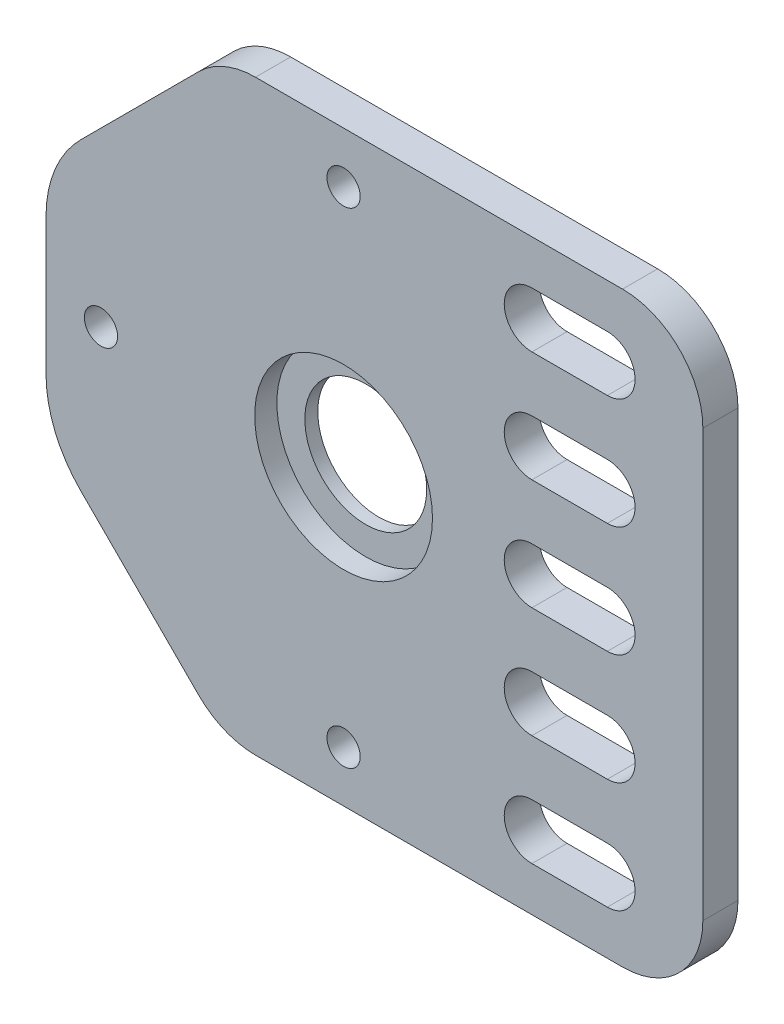
from build123d import *

# Parameters (mm, degrees)
SKETCH1_R           = 5.5
SKETCH1_R_2         = 1.5
BOSS_EXTRUDE1_DEPTH = 1.585
SKETCH3_R           = 8.025
CUT_EXTRUDE1_DEPTH  = 2


with BuildPart() as part:
    # Sketch1 → Boss-Extrude1 (new body, symmetric)
    with BuildSketch(Plane.XY):
        with BuildLine():
            Line((25.18, -26.5), (-7.946951673, -26.5))
            ThreePointArc((-7.946951673, -26.5), (-10.721406557, -25.948126611), (-13.073475836, -24.376524164))
            Line((-13.073475836, -24.376524164), (-23.731900423, -13.718099577))
            ThreePointArc((-23.731900423, -13.718099577), (-26.047033407, -10.253258212), (-26.86, -6.166199154))
            Line((-26.86, -6.166199154), (-26.86, 6.166199154))
            ThreePointArc((-26.86, 6.166199154), (-26.047033407, 10.253258212), (-23.731900423, 13.718099577))
            Line((-23.731900423, 13.718099577), (-13.073475836, 24.376524164))
            ThreePointArc((-13.073475836, 24.376524164), (-10.721406557, 25.948126611), (-7.946951673, 26.5))
            Line((-7.946951673, 26.5), (25.18, 26.5))
            ThreePointArc((25.18, 26.5), (30.306524164, 24.376524164), (32.43, 19.25))
            Line((32.43, 19.25), (32.43, -19.25))
            ThreePointArc((32.43, -19.25), (30.306524164, -24.376524164), (25.18, -26.5))
        make_face()
        Circle(SKETCH1_R, mode=Mode.SUBTRACT)
        with Locations((0, 21.9)):
            Circle(SKETCH1_R_2, mode=Mode.SUBTRACT)
        with Locations((-21.9, 0)):
            Circle(SKETCH1_R_2, mode=Mode.SUBTRACT)
        with Locations((0, -21.9)):
            Circle(SKETCH1_R_2, mode=Mode.SUBTRACT)
        with BuildLine():
            Line((17, 22.5), (23.81, 22.5))
            ThreePointArc((23.81, 22.5), (26.31, 20), (23.81, 17.5))
            Line((23.81, 17.5), (17, 17.5))
            ThreePointArc((17, 17.5), (14.5, 20), (17, 22.5))
        make_face(mode=Mode.SUBTRACT)
        with BuildLine():
            Line((17, 12.5), (23.81, 12.5))
            ThreePointArc((23.81, 12.5), (26.31, 10), (23.81, 7.5))
            Line((23.81, 7.5), (17, 7.5))
            ThreePointArc((17, 7.5), (14.5, 10), (17, 12.5))
        make_face(mode=Mode.SUBTRACT)
        with BuildLine():
            Line((17, 2.5), (23.81, 2.5))
            ThreePointArc((23.81, 2.5), (26.31, 0), (23.81, -2.5))
            Line((23.81, -2.5), (17, -2.5))
            ThreePointArc((17, -2.5), (14.5, 0), (17, 2.5))
        make_face(mode=Mode.SUBTRACT)
        with BuildLine():
            Line((17, -7.5), (23.81, -7.5))
            ThreePointArc((23.81, -7.5), (26.31, -10), (23.81, -12.5))
            Line((23.81, -12.5), (17, -12.5))
            ThreePointArc((17, -12.5), (14.5, -10), (17, -7.5))
        make_face(mode=Mode.SUBTRACT)
        with BuildLine():
            Line((17, -17.5), (23.81, -17.5))
            ThreePointArc((23.81, -17.5), (26.31, -20), (23.81, -22.5))
            Line((23.81, -22.5), (17, -22.5))
            ThreePointArc((17, -22.5), (14.5, -20), (17, -17.5))
        make_face(mode=Mode.SUBTRACT)
    extrude(amount=BOSS_EXTRUDE1_DEPTH, both=True)

    # Sketch3 → Cut-Extrude1 (cut)
    with BuildSketch(Plane.XY.offset(1.585)):
        Circle(SKETCH3_R)
    extrude(amount=-CUT_EXTRUDE1_DEPTH, mode=Mode.SUBTRACT)


solid = part.part
